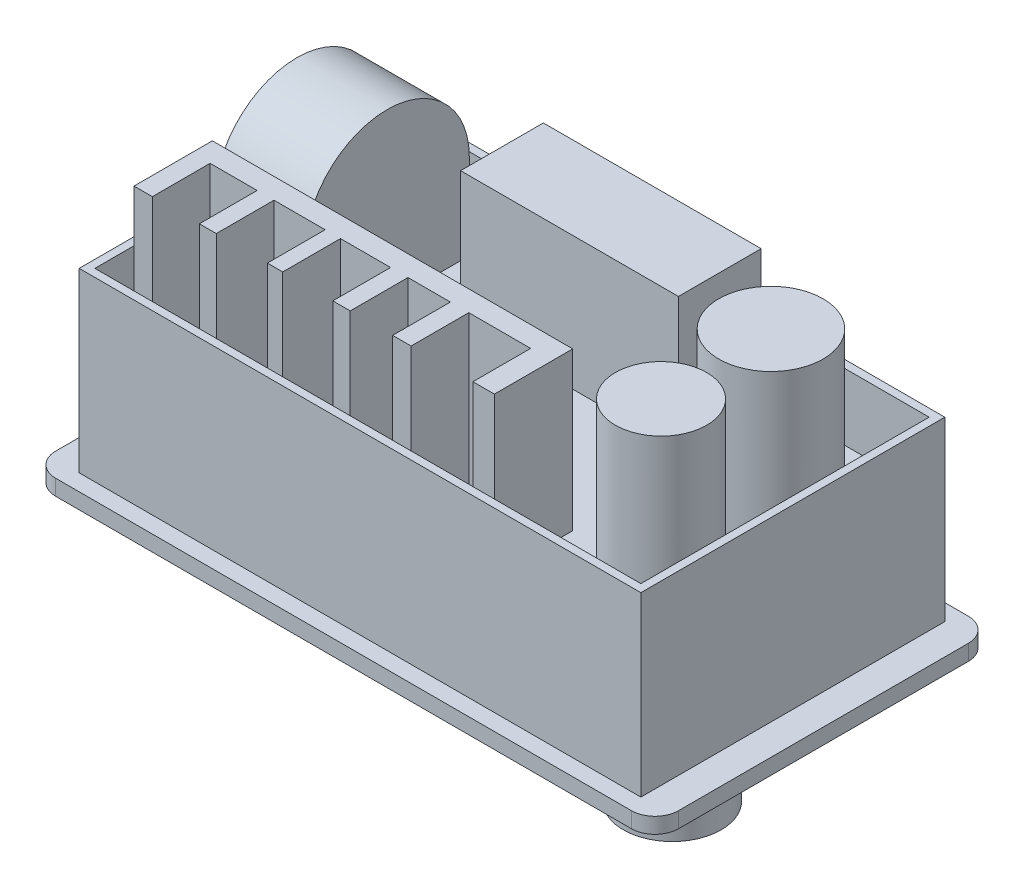
from build123d import *

# Parameters (mm, degrees)
SKETCH1_W           = 79.5
SKETCH1_H           = 43
BOSS_EXTRUDE1_DEPTH = 2
SKETCH2_W           = 71.7
SKETCH2_H           = 38.8
BOSS_EXTRUDE2_DEPTH = 22.6
SKETCH3_W           = 69.7
SKETCH3_H           = 36.8
CUT_EXTRUDE1_DEPTH  = 8.5
BOSS_EXTRUDE3_DEPTH = 22.6
SKETCH6_W           = 67.219676188
SKETCH6_H           = 8.940869551
CUT_EXTRUDE2_DEPTH  = 22.6
SKETCH7_R           = 6.66374012
SKETCH7_R_2         = 5.829163104
BOSS_EXTRUDE4_DEPTH = 20.1
FILLET1_R           = 3
SKETCH8_W           = 27.801535977
SKETCH8_H           = 10.55826339
BOSS_EXTRUDE5_DEPTH = 17
SKETCH9_W           = 67.5
SKETCH9_H           = 31
CUT_EXTRUDE3_DEPTH  = 1
SKETCH10_W          = 28.845725121
SKETCH10_H          = 25.974204973
CUT_EXTRUDE4_DEPTH  = 1
SKETCH11_R          = 6.25
BOSS_EXTRUDE6_DEPTH = 12
BOSS_EXTRUDE7_START = 2.5
BOSS_EXTRUDE7_DEPTH = 11.5


with BuildPart() as part:
    # Sketch1 → Boss-Extrude1 (new body)
    with BuildSketch(Plane(origin=(0, 0, 0), x_dir=(1, 0, 0), z_dir=(0, 1, 0))):
        with Locations((25.074854651, -17.802325581)):
            Rectangle(SKETCH1_W, SKETCH1_H)
    extrude(amount=BOSS_EXTRUDE1_DEPTH)

    # Sketch2 → Boss-Extrude2 (add)
    with BuildSketch(Plane(origin=(0, 2, 0), x_dir=(1, 0, 0), z_dir=(0, 1, 0))):
        with Locations((25.074854651, -17.802325581)):
            Rectangle(SKETCH2_W, SKETCH2_H)
    extrude(amount=BOSS_EXTRUDE2_DEPTH)

    # Sketch3 → Cut-Extrude1 (cut)
    with BuildSketch(Plane(origin=(0, 24.6, 0), x_dir=(1, 0, 0), z_dir=(0, 1, 0))):
        with Locations((25.074854651, -17.802325581)):
            Rectangle(SKETCH3_W, SKETCH3_H)
    extrude(amount=-CUT_EXTRUDE1_DEPTH, mode=Mode.SUBTRACT)

    # Sketch5 → Boss-Extrude3 (add)
    with BuildSketch(Plane(origin=(0, 16.1, 0), x_dir=(1, 0, 0), z_dir=(0, 1, 0))):
        Polygon((41.224854651, -26.202325581), (-4.775145349, -26.202325581), (-4.775145349, -36.202325581), (-2.433003128, -36.202325581), (-2.433003128, -28.831573422), (3.571084453, -28.831573422), (3.571084453, -36.202325581), (5.724724564, -36.202325581), (5.724724564, -28.831573422), (12.250906718, -28.831573422), (12.250906718, -36.202325581), (14.208761365, -36.202325581), (14.208761365, -28.831573422), (20.604419876, -28.831573422), (20.604419876, -36.202325581), (22.823321808, -36.202325581), (22.823321808, -28.831573422), (28.240052996, -28.831573422), (28.240052996, -36.202325581), (30.589478571, -36.202325581), (30.589478571, -28.831573422), (38.486158978, -28.831573422), (38.486158978, -36.202325581), (41.224854651, -36.202325581), align=None)
    extrude(amount=BOSS_EXTRUDE3_DEPTH)

    # Sketch6 → Cut-Extrude2 (cut)
    with BuildSketch(Plane.XY.offset(37.202325581)):
        with Locations((18.972874337, 40.670434775)):
            Rectangle(SKETCH6_W, SKETCH6_H)
    extrude(amount=-CUT_EXTRUDE2_DEPTH, mode=Mode.SUBTRACT)

    # Sketch7 → Boss-Extrude4 (add)
    with BuildSketch(Plane(origin=(0, 16.1, 0), x_dir=(1, 0, 0), z_dir=(0, 1, 0))):
        with Locations((51.669046929, -11.341405249)):
            Circle(SKETCH7_R)
        with Locations((52.386926966, -26.090576917)):
            Circle(SKETCH7_R_2)
    extrude(amount=BOSS_EXTRUDE4_DEPTH)

    # Fillet1
    fillet1_edges = [part.edges().sort_by_distance(p)[0] for p in [
        (-14.675145349, 1, -3.697674419),
        (64.824854651, 1, -3.697674419),
        (64.824854651, 1, 39.302325581),
        (-14.675145349, 1, 39.302325581),
    ]]
    fillet(fillet1_edges, radius=FILLET1_R)

    # Sketch8 → Boss-Extrude5 (add)
    with BuildSketch(Plane(origin=(0, 16.1, 0), x_dir=(1, 0, 0), z_dir=(0, 1, 0))):
        with Locations((25.172747384, -5.279131695)):
            Rectangle(SKETCH8_W, SKETCH8_H)
    extrude(amount=BOSS_EXTRUDE5_DEPTH)

    # Sketch9 → Cut-Extrude3 (cut)
    with BuildSketch(Plane.XZ):
        with Locations((25.074854651, 17.802325581)):
            Rectangle(SKETCH9_W, SKETCH9_H)
    extrude(amount=-CUT_EXTRUDE3_DEPTH, mode=Mode.SUBTRACT)

    # Sketch10 → Cut-Extrude4 (cut)
    with BuildSketch(Plane.XZ.offset(-1)):
        with Locations((18.581303408, 17.606540116)):
            Rectangle(SKETCH10_W, SKETCH10_H)
    extrude(amount=-CUT_EXTRUDE4_DEPTH, mode=Mode.SUBTRACT)

    # Sketch11 → Boss-Extrude6 (add)
    with BuildSketch(Plane.XZ.offset(-1)):
        with Locations((50.42907232, 22.696962197)):
            Circle(SKETCH11_R)
    extrude(amount=BOSS_EXTRUDE6_DEPTH)

    # Sketch12 → Boss-Extrude7 (add)
    with BuildSketch(Plane(origin=(-9.775145349, 0, 0), x_dir=(0, 0, -1), z_dir=(1, 0, 0)).offset(BOSS_EXTRUDE7_START)):
        with BuildLine():
            Line((-23.402325581, 16.1), (-23.402325581, 27))
            ThreePointArc((-23.402325581, 27), (-12.902325581, 37.5), (-2.402325581, 27))
            Line((-2.402325581, 27), (-2.402325581, 16.1))
            ThreePointArc((-2.402325581, 16.1), (-12.902325581, 5.6), (-23.402325581, 16.1))
        make_face()
    extrude(amount=BOSS_EXTRUDE7_DEPTH)


solid = part.part
